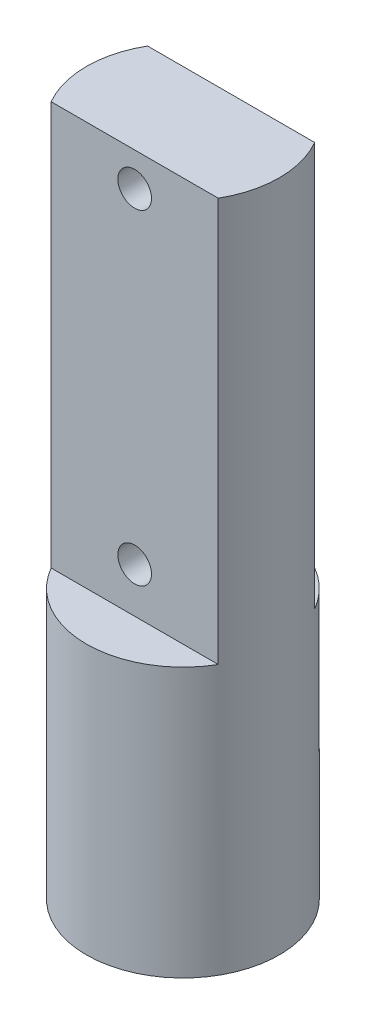
from build123d import *

# Parameters (mm, degrees)
SKETCH2_R           = 4.3
BOSS_EXTRUDE2_DEPTH = 30
CUT_EXTRUDE2_DEPTH  = 18
SKETCH6_R           = 0.75
CUT_EXTRUDE3_DEPTH  = 10
SKETCH8_R           = 0.75
CUT_EXTRUDE5_DEPTH  = 5.3
SKETCH9_R           = 0.75
CUT_EXTRUDE6_DEPTH  = 10


with BuildPart() as part:
    # Sketch2 → Boss-Extrude2 (new body)
    with BuildSketch(Plane(origin=(0, 0, 0), x_dir=(1, 0, 0), z_dir=(0, 1, 0))):
        Circle(SKETCH2_R)
    extrude(amount=BOSS_EXTRUDE2_DEPTH)

    # Sketch4 → Cut-Extrude2 (cut)
    with BuildSketch(Plane(origin=(0, 30, 0), x_dir=(1, 0, 0), z_dir=(0, 1, 0))):
        with BuildLine():
            Line((0, 2.15), (-3.723909236, 2.15))
            ThreePointArc((-3.723909236, 2.15), (0, 4.3), (3.723909236, 2.15))
            Line((3.723909236, 2.15), (0, 2.15))
        make_face()
        with BuildLine():
            Line((0, -2.15), (-3.723909236, -2.15))
            ThreePointArc((-3.723909236, -2.15), (0, -4.3), (3.723909236, -2.15))
            Line((3.723909236, -2.15), (0, -2.15))
        make_face()
    extrude(amount=-CUT_EXTRUDE2_DEPTH, mode=Mode.SUBTRACT)

    # Sketch6 → Cut-Extrude3 (cut)
    with BuildSketch(Plane.XY.offset(2.15)):
        with Locations((0, 14)):
            Circle(SKETCH6_R)
    extrude(amount=-CUT_EXTRUDE3_DEPTH, mode=Mode.SUBTRACT)

    # Sketch8 → Cut-Extrude5 (cut, through all)
    with BuildSketch(Plane(origin=(0, 0, 0), x_dir=(0, 0, -1), z_dir=(1, 0, 0))):
        with Locations((0, 1)):
            Circle(SKETCH8_R)
    extrude(amount=-CUT_EXTRUDE5_DEPTH, mode=Mode.SUBTRACT)

    # Sketch9 → Cut-Extrude6 (cut)
    with BuildSketch(Plane.XY.offset(2.15)):
        with Locations((0, 28.5)):
            Circle(SKETCH9_R)
    extrude(amount=-CUT_EXTRUDE6_DEPTH, mode=Mode.SUBTRACT)


solid = part.part
